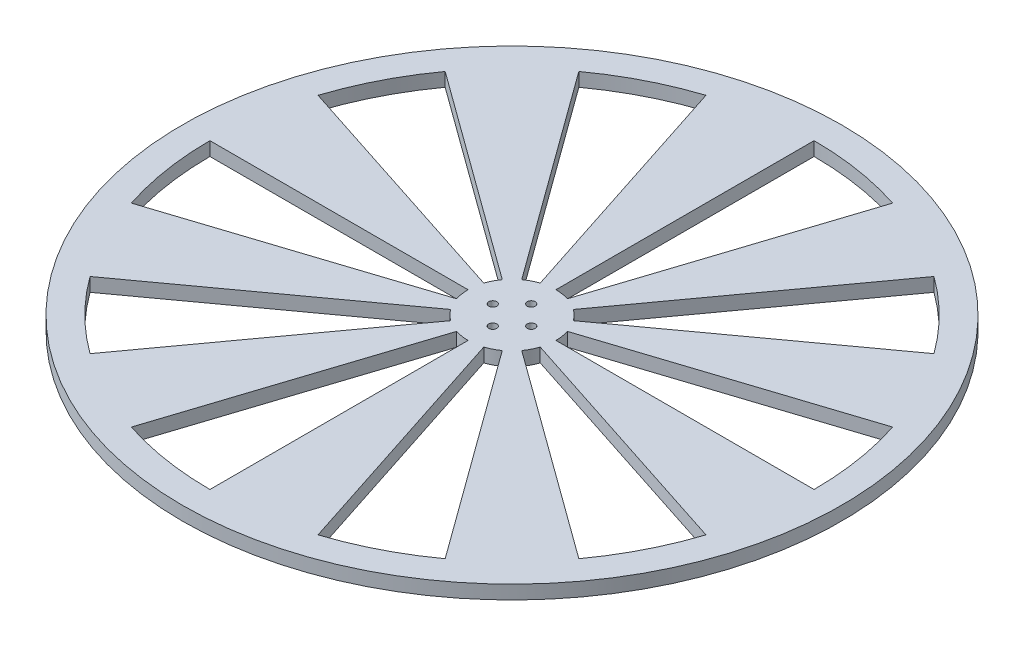
from build123d import *

# Parameters (mm, degrees)
SKETCH_1_R      = 120
SKETCH_1_R_2    = 1.45
EXTRUDE_1_DEPTH = 2.5


with BuildPart() as part:
    # 草图1 → 凸台-拉伸1 (new body, symmetric)
    with BuildSketch(Plane(origin=(0, 0, 0), x_dir=(1, 0, 0), z_dir=(0, 1, 0))):
        Circle(SKETCH_1_R)
        with Locations((7, 0)):
            Circle(SKETCH_1_R_2, mode=Mode.SUBTRACT)
        with Locations((0, 7)):
            Circle(SKETCH_1_R_2, mode=Mode.SUBTRACT)
        with Locations((-7, 0)):
            Circle(SKETCH_1_R_2, mode=Mode.SUBTRACT)
        with Locations((0, -7)):
            Circle(SKETCH_1_R_2, mode=Mode.SUBTRACT)
        with BuildLine():
            Line((16, 0), (110, 0))
            ThreePointArc((110, 0), (108.645717465, 17.207791154), (104.616216792, 33.991869381))
            Line((104.616216792, 33.991869381), (15.216904261, 4.94427191))
            ThreePointArc((15.216904261, 4.94427191), (15.80301345, 2.502951441), (16, 0))
        make_face(mode=Mode.SUBTRACT)
        with BuildLine():
            Line((9.404564037, 12.94427191), (64.656377752, 88.991869381))
            ThreePointArc((64.656377752, 88.991869381), (77.781745931, 77.781745931), (88.991869381, 64.656377752))
            Line((88.991869381, 64.656377752), (12.94427191, 9.404564037))
            ThreePointArc((12.94427191, 9.404564037), (11.313708499, 11.313708499), (9.404564037, 12.94427191))
        make_face(mode=Mode.SUBTRACT)
        with BuildLine():
            Line((0, 16), (0, 110))
            ThreePointArc((0, 110), (17.207791154, 108.645717465), (33.991869381, 104.616216792))
            Line((33.991869381, 104.616216792), (4.94427191, 15.216904261))
            ThreePointArc((4.94427191, 15.216904261), (2.502951441, 15.80301345), (0, 16))
        make_face(mode=Mode.SUBTRACT)
        with BuildLine():
            Line((-9.404564037, 12.94427191), (-64.656377752, 88.991869381))
            ThreePointArc((-64.656377752, 88.991869381), (-49.938954971, 98.010717661), (-33.991869381, 104.616216792))
            Line((-33.991869381, 104.616216792), (-4.94427191, 15.216904261))
            ThreePointArc((-4.94427191, 15.216904261), (-7.263847996, 14.256104387), (-9.404564037, 12.94427191))
        make_face(mode=Mode.SUBTRACT)
        with BuildLine():
            Line((-15.216904261, 4.94427191), (-104.616216792, 33.991869381))
            ThreePointArc((-104.616216792, 33.991869381), (-98.010717661, 49.938954971), (-88.991869381, 64.656377752))
            Line((-88.991869381, 64.656377752), (-12.94427191, 9.404564037))
            ThreePointArc((-12.94427191, 9.404564037), (-14.256104387, 7.263847996), (-15.216904261, 4.94427191))
        make_face(mode=Mode.SUBTRACT)
        with BuildLine():
            Line((-15.216904261, -4.94427191), (-104.616216792, -33.991869381))
            ThreePointArc((-104.616216792, -33.991869381), (-108.645717465, -17.207791154), (-110, 0))
            Line((-110, 0), (-16, 0))
            ThreePointArc((-16, 0), (-15.80301345, -2.502951441), (-15.216904261, -4.94427191))
        make_face(mode=Mode.SUBTRACT)
        with BuildLine():
            Line((-9.404564037, -12.94427191), (-64.656377752, -88.991869381))
            ThreePointArc((-64.656377752, -88.991869381), (-77.781745931, -77.781745931), (-88.991869381, -64.656377752))
            Line((-88.991869381, -64.656377752), (-12.94427191, -9.404564037))
            ThreePointArc((-12.94427191, -9.404564037), (-11.313708499, -11.313708499), (-9.404564037, -12.94427191))
        make_face(mode=Mode.SUBTRACT)
        with BuildLine():
            Line((0, -16), (0, -110))
            ThreePointArc((0, -110), (-17.207791154, -108.645717465), (-33.991869381, -104.616216792))
            Line((-33.991869381, -104.616216792), (-4.94427191, -15.216904261))
            ThreePointArc((-4.94427191, -15.216904261), (-2.502951441, -15.80301345), (0, -16))
        make_face(mode=Mode.SUBTRACT)
        with BuildLine():
            Line((9.404564037, -12.94427191), (64.656377752, -88.991869381))
            ThreePointArc((64.656377752, -88.991869381), (49.938954971, -98.010717661), (33.991869381, -104.616216792))
            Line((33.991869381, -104.616216792), (4.94427191, -15.216904261))
            ThreePointArc((4.94427191, -15.216904261), (7.263847996, -14.256104387), (9.404564037, -12.94427191))
        make_face(mode=Mode.SUBTRACT)
        with BuildLine():
            Line((15.216904261, -4.94427191), (104.616216792, -33.991869381))
            ThreePointArc((104.616216792, -33.991869381), (98.010717661, -49.938954971), (88.991869381, -64.656377752))
            Line((88.991869381, -64.656377752), (12.94427191, -9.404564037))
            ThreePointArc((12.94427191, -9.404564037), (14.256104387, -7.263847996), (15.216904261, -4.94427191))
        make_face(mode=Mode.SUBTRACT)
    extrude(amount=EXTRUDE_1_DEPTH, both=True)


solid = part.part
